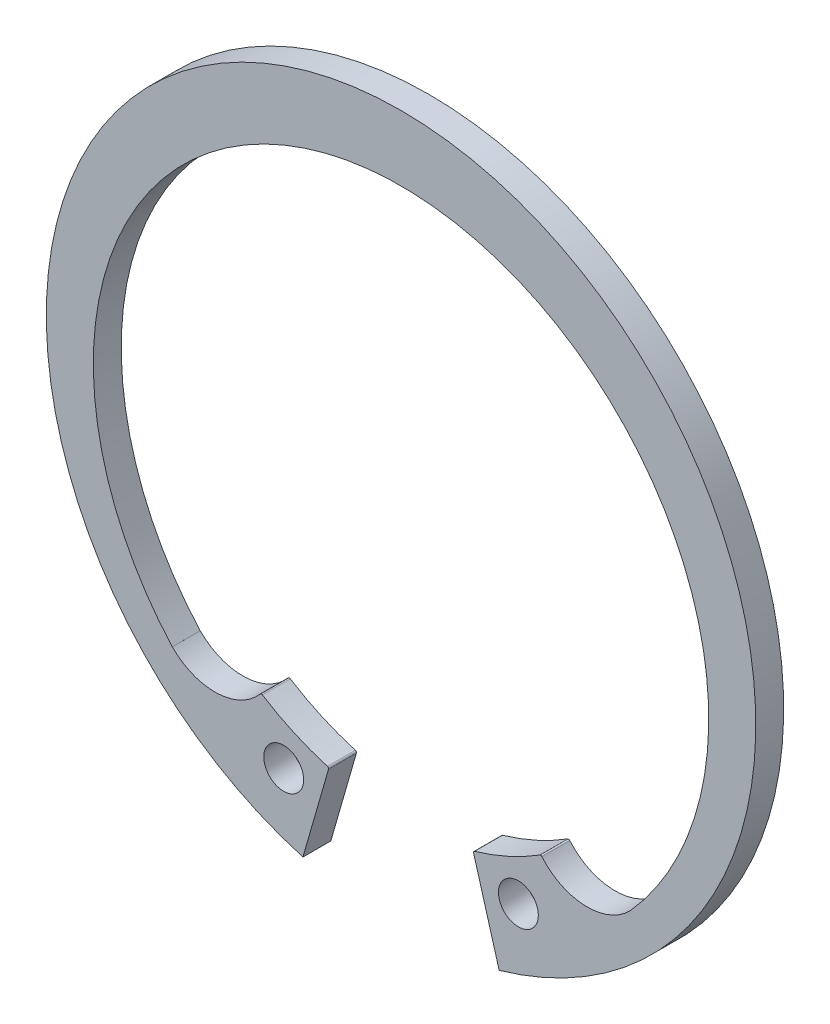
from build123d import *

# Parameters (mm, degrees)
BODYSKE_R    = 1.25
BODY_DEPTH   = 1.75
MODLUGSKE_R  = 1.25
MODLUG_DEPTH = 1.75


with BuildPart() as part:
    # BodySke → Body (new body)
    with BuildSketch(Plane.XY):
        with BuildLine():
            Line((6.15473831, -21.381807602), (5.12564003, -17.806678924))
            ThreePointArc((5.12564003, -17.806678924), (6.26268227, -15.113739212), (9.13415023, -15.660969609))
            ThreePointArc((9.13415023, -15.660969609), (10.710697658, -16.474976548), (12.402371606, -15.939861288))
            ThreePointArc((12.402371606, -15.939861288), (0, 18.15), (-12.402371606, -15.939861288))
            ThreePointArc((-12.402371606, -15.939861288), (-10.710697658, -16.474976548), (-9.13415023, -15.660969609))
            ThreePointArc((-9.13415023, -15.660969609), (-6.26268227, -15.113739212), (-5.12564003, -17.806678924))
            Line((-5.12564003, -17.806678924), (-6.15473831, -21.381807602))
            ThreePointArc((-6.15473831, -21.381807602), (0, 22.25), (6.15473831, -21.381807602))
        make_face()
        with Locations((7.359918802, -17.163543347)):
            Circle(BODYSKE_R, mode=Mode.SUBTRACT)
        with Locations((-7.359918802, -17.163543347)):
            Circle(BODYSKE_R, mode=Mode.SUBTRACT)
    extrude(amount=-BODY_DEPTH)

    # ModLugSke → ModLug (add, through all)
    with BuildSketch(Plane.XY):
        with BuildLine():
            Line((6.15473831, -21.381807602), (4.550273009, -15.80783083))
            ThreePointArc((4.550273009, -15.80783083), (4.558712973, -15.732043553), (4.618125604, -15.684241005))
            ThreePointArc((4.618125604, -15.684241005), (6.723383791, -14.903644199), (8.701845472, -13.841979099))
            ThreePointArc((8.701845472, -13.841979099), (8.770273624, -13.827802373), (8.831276161, -13.861891696))
            ThreePointArc((8.831276161, -13.861891696), (11.5450024, -15.176170025), (14.345137247, -14.057741457))
            Line((14.345137247, -14.057741457), (15.89150871, -15.573132342))
            ThreePointArc((15.89150871, -15.573132342), (11.399317041, -19.108062984), (6.15473831, -21.381807602))
        make_face()
        with Locations((7.359918802, -17.163543347)):
            Circle(MODLUGSKE_R, mode=Mode.SUBTRACT)
        with BuildLine():
            Line((-6.15473831, -21.381807602), (-4.550273009, -15.80783083))
            ThreePointArc((-4.550273009, -15.80783083), (-4.558712973, -15.732043553), (-4.618125604, -15.684241005))
            ThreePointArc((-4.618125604, -15.684241005), (-6.723383791, -14.903644199), (-8.701845472, -13.841979099))
            ThreePointArc((-8.701845472, -13.841979099), (-8.770273624, -13.827802373), (-8.831276161, -13.861891696))
            ThreePointArc((-8.831276161, -13.861891696), (-11.5450024, -15.176170025), (-14.345137247, -14.057741457))
            Line((-14.345137247, -14.057741457), (-15.89150871, -15.573132342))
            ThreePointArc((-15.89150871, -15.573132342), (-11.399317041, -19.108062984), (-6.15473831, -21.381807602))
        make_face()
        with Locations((-7.359918802, -17.163543347)):
            Circle(MODLUGSKE_R, mode=Mode.SUBTRACT)
    extrude(amount=-MODLUG_DEPTH)


solid = part.part
